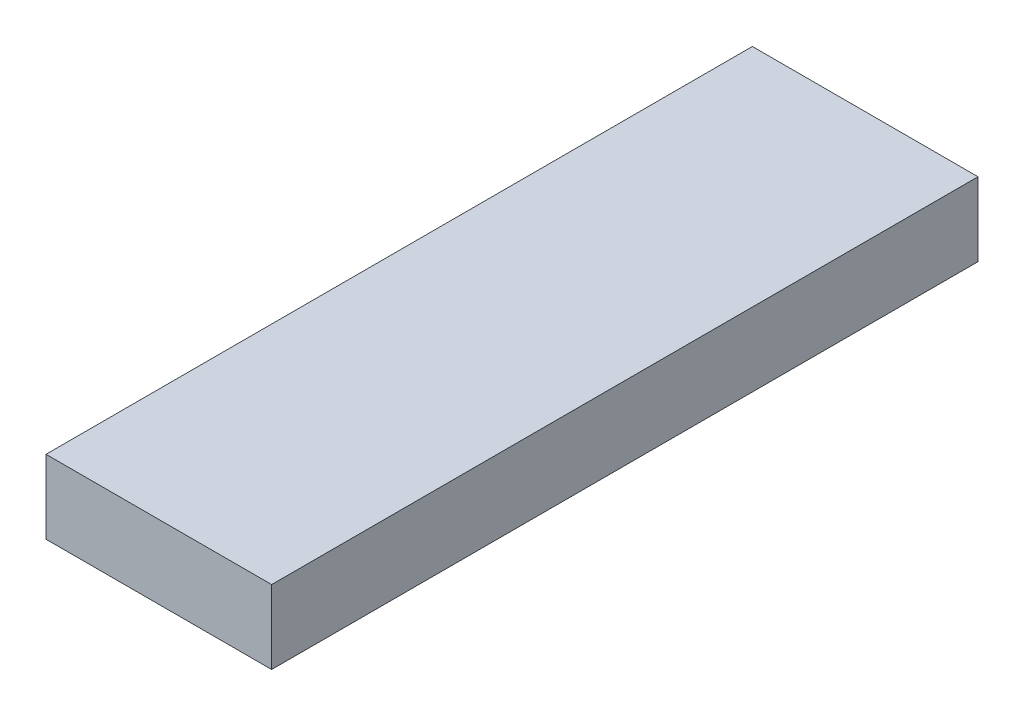
from build123d import *

# Parameters (mm, degrees)
SKETCH1_W           = 46
SKETCH1_H           = 144
BOSS_EXTRUDE1_DEPTH = 15


with BuildPart() as part:
    # Sketch1 → Boss-Extrude1 (new body)
    with BuildSketch(Plane(origin=(0, 0, 0), x_dir=(1, 0, 0), z_dir=(0, 1, 0))):
        Rectangle(SKETCH1_W, SKETCH1_H)
    extrude(amount=BOSS_EXTRUDE1_DEPTH)


solid = part.part
